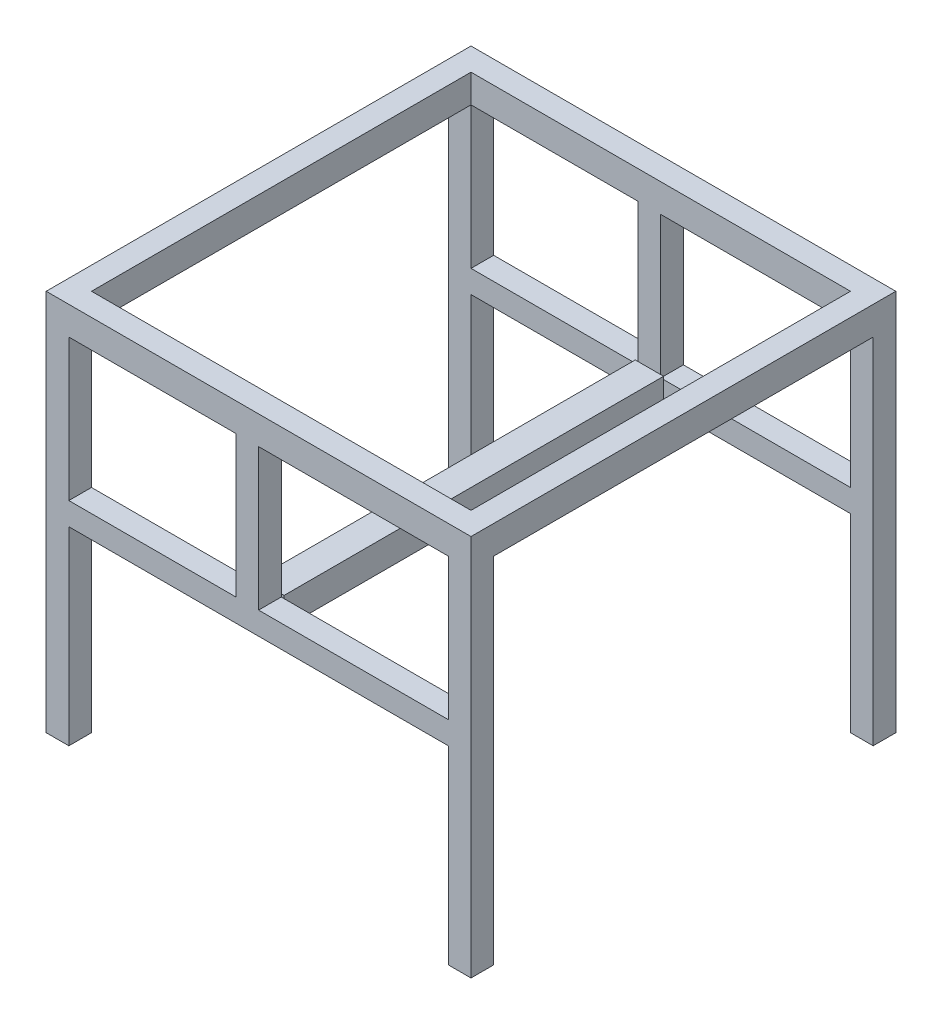
from build123d import *

# Parameters (mm, degrees)
SKETCH1_W           = 300
SKETCH1_H           = 300
SKETCH1_W_2         = 268
SKETCH1_H_2         = 268
BOSS_EXTRUDE1_DEPTH = 20
SKETCH3_W           = 16
SKETCH3_H           = 100
BOSS_EXTRUDE2_DEPTH = 16
SKETCH4_W           = 16
SKETCH4_H           = 250
BOSS_EXTRUDE3_DEPTH = 16
SKETCH5_W           = 268
SKETCH5_H           = 16
BOSS_EXTRUDE4_DEPTH = 16
SKETCH6_W           = 20
SKETCH6_H           = 20
BOSS_EXTRUDE5_DEPTH = 268


with BuildPart() as part:
    # Sketch1 → Boss-Extrude1 (new body)
    with BuildSketch(Plane(origin=(0, 0, 0), x_dir=(1, 0, 0), z_dir=(0, 1, 0))):
        Rectangle(SKETCH1_W, SKETCH1_H)
        Rectangle(SKETCH1_W_2, SKETCH1_H_2, mode=Mode.SUBTRACT)
    extrude(amount=BOSS_EXTRUDE1_DEPTH)

    # Sketch3 → Boss-Extrude2 (add)
    with BuildSketch(Plane.XY.offset(150)):
        with Locations((-8, -50)):
            Rectangle(SKETCH3_W, SKETCH3_H)
    boss_extrude2 = extrude(amount=-BOSS_EXTRUDE2_DEPTH)

    # Sketch4 → Boss-Extrude3 (add)
    with BuildSketch(Plane.XY.offset(150)):
        with Locations((-142, -125)):
            Rectangle(SKETCH4_W, SKETCH4_H)
        with Locations((142, -125)):
            Rectangle(SKETCH4_W, SKETCH4_H)
    boss_extrude3 = extrude(amount=-BOSS_EXTRUDE3_DEPTH)

    # Sketch5 → Boss-Extrude4 (add)
    with BuildSketch(Plane.XY.offset(150)):
        with Locations((0, -108)):
            Rectangle(SKETCH5_W, SKETCH5_H)
    boss_extrude4 = extrude(amount=-BOSS_EXTRUDE4_DEPTH)

    # Mirror1: Boss-Extrude2, Boss-Extrude3, Boss-Extrude4 across plane
    add(boss_extrude2.mirror(Plane.XY))
    add(boss_extrude3.mirror(Plane.XY))
    add(boss_extrude4.mirror(Plane.XY))

    # Sketch6 → Boss-Extrude5 (add)
    with BuildSketch(Plane(origin=(0, 0, 134), x_dir=(-1, 0, 0), z_dir=(0, 0, -1))):
        with Locations((8, -108)):
            Rectangle(SKETCH6_W, SKETCH6_H)
    extrude(amount=BOSS_EXTRUDE5_DEPTH)


solid = part.part
